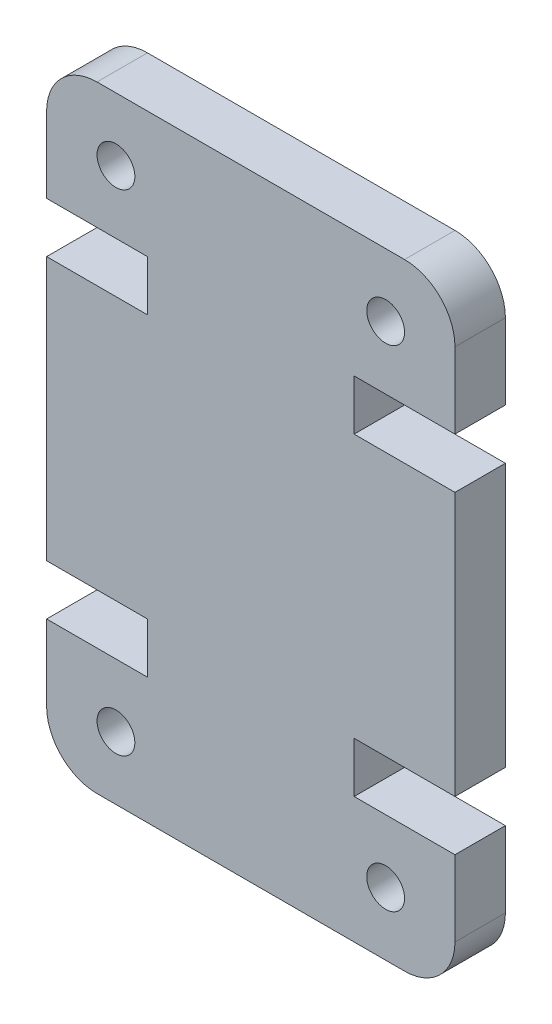
from build123d import *

# Parameters (mm, degrees)
SKETCH1_R           = 0.75
BOSS_EXTRUDE1_DEPTH = 2


with BuildPart() as part:
    # Sketch1 → Boss-Extrude1 (new body)
    with BuildSketch(Plane.XY):
        with BuildLine():
            Line((0, 17.45), (0, 7))
            Line((0, 7), (4, 7))
            Line((4, 7), (4, 5))
            Line((4, 5), (0, 5))
            Line((0, 5), (0, 2))
            ThreePointArc((0, 2), (0.585786438, 0.585786438), (2, 0))
            Line((2, 0), (14.2, 0))
            ThreePointArc((14.2, 0), (15.614213562, 0.585786438), (16.2, 2))
            Line((16.2, 2), (16.2, 5))
            Line((16.2, 5), (12.2, 5))
            Line((12.2, 5), (12.2, 7))
            Line((12.2, 7), (16.2, 7))
            Line((16.2, 7), (16.2, 17.45))
            Line((16.2, 17.45), (12.2, 17.45))
            Line((12.2, 17.45), (12.2, 19.45))
            Line((12.2, 19.45), (16.2, 19.45))
            Line((16.2, 19.45), (16.2, 22.45))
            ThreePointArc((16.2, 22.45), (15.614213562, 23.864213562), (14.2, 24.45))
            Line((14.2, 24.45), (2, 24.45))
            ThreePointArc((2, 24.45), (0.585786438, 23.864213562), (0, 22.45))
            Line((0, 22.45), (0, 19.45))
            Line((0, 19.45), (4, 19.45))
            Line((4, 19.45), (4, 17.45))
            Line((4, 17.45), (0, 17.45))
        make_face()
        with Locations((13.45, 2.5)):
            Circle(SKETCH1_R, mode=Mode.SUBTRACT)
        with Locations((2.75, 21.95)):
            Circle(SKETCH1_R, mode=Mode.SUBTRACT)
        with Locations((2.75, 2.5)):
            Circle(SKETCH1_R, mode=Mode.SUBTRACT)
        with Locations((13.45, 21.95)):
            Circle(SKETCH1_R, mode=Mode.SUBTRACT)
    extrude(amount=BOSS_EXTRUDE1_DEPTH)


solid = part.part
